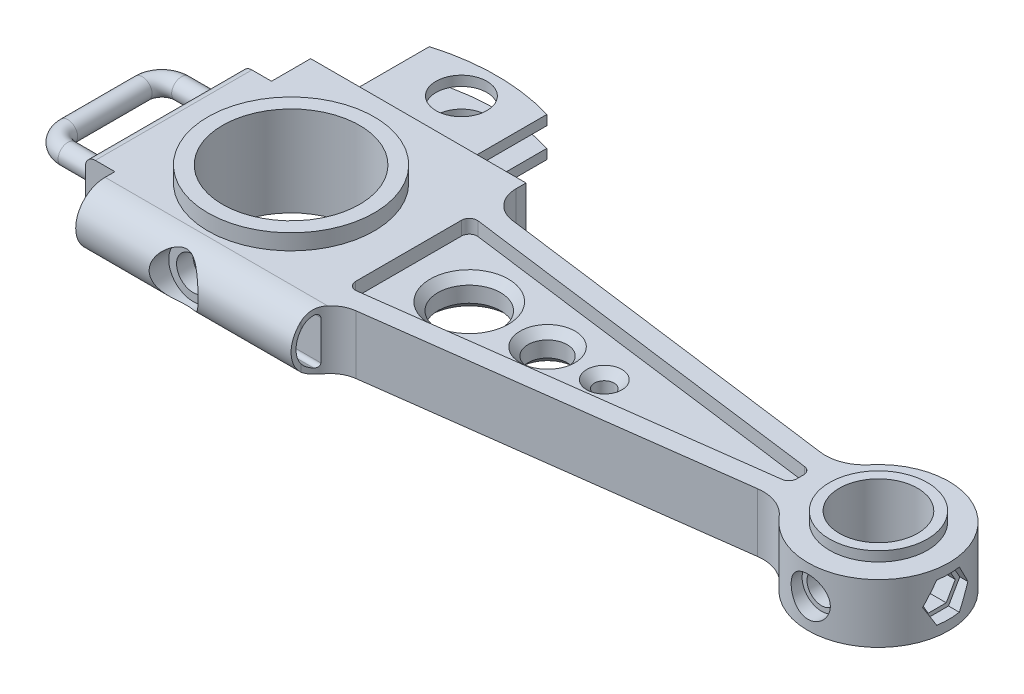
from build123d import *

# Parameters (mm, degrees)
SKETCH1_R           = 22.225
SKETCH1_R_2         = 12.7
BOSS_EXTRUDE2_DEPTH = 9.525
SKETCH3_R           = 15.875
SKETCH3_R_2         = 12.7
BOSS_EXTRUDE3_DEPTH = 12.7
CUT_EXTRUDE5_REACH  = 78.2
SKETCH7_R           = 5.3975
SKETCH8_R           = 7.9375
CUT_EXTRUDE6_DEPTH  = 6.35
SKETCH4_R           = 26.9875
SKETCH4_R_2         = 22.225
BOSS_EXTRUDE4_DEPTH = 14.605
CUT_EXTRUDE2_DEPTH  = 40.64
CUT_EXTRUDE4_DEPTH  = 12.7
SKETCH10_R          = 8.255
BOSS_EXTRUDE5_DEPTH = 6.35
FILLET1_R           = 1.27
SKETCH11_W          = 24.765
SKETCH11_H          = 6.35
CUT_EXTRUDE7_DEPTH  = 61.325
SKETCH12_R          = 3.175
FILLET2_R           = 2.54
FILLET3_R           = 3.175
CUT_EXTRUDE8_DEPTH  = 4.445
SKETCH15_R          = 10.16
SKETCH15_R_2        = 6.35
SKETCH15_R_3        = 3.175
CUT_EXTRUDE9_DEPTH  = 20.685
CHAMFER1_SIZE       = 2.54
SKETCH16_R          = 4.7625
CUT_EXTRUDE10_DEPTH = 39.1000001
CUT_EXTRUDE11_START = 18.415
SKETCH17_R          = 6.35
CUT_EXTRUDE11_DEPTH = 4.445
CUT_EXTRUDE12_START = 190.5
CUT_EXTRUDE12_DEPTH = 23.8600001
CUT_EXTRUDE13_START = 209.55
CUT_EXTRUDE13_DEPTH = 4.8100001


with BuildPart() as part:
    # Sketch1 → Boss-Extrude2 (new body, symmetric)
    with BuildSketch(Plane(origin=(0, 0, 0), x_dir=(1, 0, 0), z_dir=(0, 1, 0))):
        with BuildLine():
            Line((-41.275, 25.4), (-41.275, -25.4))
            Line((-41.275, -25.4), (-31.75, -25.4))
            Line((-31.75, -25.4), (-31.75, -38.1))
            Line((-31.75, -38.1), (38.1, -38.1))
            Line((38.1, -38.1), (38.1, -34.82000081))
            ThreePointArc((38.1, -34.82000081), (40.463725834, -28.539731921), (46.381738019, -25.376488505))
            Line((46.381738019, -25.376488505), (161.557504049, -10.213311246))
            ThreePointArc((161.557504049, -10.213311246), (167.829623981, -10.972629525), (172.959762872, -14.660139205))
            ThreePointArc((172.959762872, -14.660139205), (213.36, 0), (172.959762872, 14.660139205))
            ThreePointArc((172.959762872, 14.660139205), (167.829623981, 10.972629525), (161.557504049, 10.213311246))
            Line((161.557504049, 10.213311246), (46.381738019, 25.376488505))
            ThreePointArc((46.381738019, 25.376488505), (40.463725834, 28.539731921), (38.1, 34.82000081))
            Line((38.1, 34.82000081), (38.1, 38.1))
            Line((38.1, 38.1), (-31.75, 38.1))
            Line((-31.75, 38.1), (-31.75, 25.4))
            Line((-31.75, 25.4), (-41.275, 25.4))
        make_face()
        Circle(SKETCH1_R, mode=Mode.SUBTRACT)
        with Locations((190.5, 0)):
            Circle(SKETCH1_R_2, mode=Mode.SUBTRACT)
    extrude(amount=BOSS_EXTRUDE2_DEPTH, both=True)

    # Sketch3 → Boss-Extrude3 (add, symmetric)
    with BuildSketch(Plane(origin=(0, 0, 0), x_dir=(1, 0, 0), z_dir=(0, 1, 0))):
        with Locations((190.5, 0)):
            Circle(SKETCH3_R)
        with Locations((190.5, 0)):
            Circle(SKETCH3_R_2, mode=Mode.SUBTRACT)
    extrude(amount=BOSS_EXTRUDE3_DEPTH, both=True)

    # Sketch7 → Cut-Extrude5 (cut, up to next)
    with BuildSketch(Plane.XY.offset(38.1), mode=Mode.PRIVATE) as cut_extrude5_sk1:
        Circle(SKETCH7_R)
    cut_extrude5_tool1 = extrude(cut_extrude5_sk1.sketch, amount=-CUT_EXTRUDE5_REACH, mode=Mode.PRIVATE) & part.part
    add(cut_extrude5_tool1.solids().sort_by_distance((0, 0, 38.1))[0], mode=Mode.SUBTRACT)

    # Sketch8 → Cut-Extrude6 (cut)
    with BuildSketch(Plane.XY.offset(38.1)):
        Circle(SKETCH8_R)
    extrude(amount=-CUT_EXTRUDE6_DEPTH, mode=Mode.SUBTRACT)

    # Sketch4 → Boss-Extrude4 (add, symmetric)
    with BuildSketch(Plane(origin=(0, 0, 0), x_dir=(1, 0, 0), z_dir=(0, 1, 0))):
        Circle(SKETCH4_R)
        Circle(SKETCH4_R_2, mode=Mode.SUBTRACT)
    extrude(amount=BOSS_EXTRUDE4_DEPTH, both=True)

    # Sketch5 → Cut-Extrude2 (cut, symmetric)
    with BuildSketch(Plane(origin=(0, 0, 0), x_dir=(0, 0, -1), z_dir=(1, 0, 0))):
        with BuildLine():
            Line((-28.575, 9.525), (-38.1, 9.525))
            Line((-38.1, 9.525), (-38.1, 0))
            ThreePointArc((-38.1, 0), (-35.310192091, 6.735192091), (-28.575, 9.525))
        make_face()
        with BuildLine():
            ThreePointArc((-28.575, -9.525), (-35.310192091, -6.735192091), (-38.1, 0))
            Line((-38.1, 0), (-38.1, -9.525))
            Line((-38.1, -9.525), (-28.575, -9.525))
        make_face()
    extrude(amount=CUT_EXTRUDE2_DEPTH, both=True, mode=Mode.SUBTRACT)

    # Sketch6 → Cut-Extrude4 (cut, symmetric)
    with BuildSketch(Plane(origin=(38.1, 0, 0), x_dir=(0, 0, -1), z_dir=(1, 0, 0))):
        with BuildLine():
            Line((-29.845, 6.337999861), (-29.845, -6.337999861))
            ThreePointArc((-29.845, -6.337999861), (-30.339306083, -7.279087106), (-31.394685393, -7.406202085))
            ThreePointArc((-31.394685393, -7.406202085), (-36.4998, 0), (-31.394685393, 7.406202085))
            ThreePointArc((-31.394685393, 7.406202085), (-30.339306083, 7.279087106), (-29.845, 6.337999861))
        make_face()
    extrude(amount=CUT_EXTRUDE4_DEPTH, both=True, mode=Mode.SUBTRACT)

    # Sketch10 → Boss-Extrude5 (add, symmetric)
    with BuildSketch(Plane(origin=(0, 0, 0), x_dir=(1, 0, 0), z_dir=(0, 1, 0))):
        with BuildLine():
            Line((-19.05, 38.1), (-19.05, 63.895642457))
            ThreePointArc((-19.05, 63.895642457), (0, 66.675), (19.05, 63.895642457))
            Line((19.05, 63.895642457), (19.05, 38.1))
            Line((19.05, 38.1), (-19.05, 38.1))
        make_face()
        with Locations((0, 55.245)):
            Circle(SKETCH10_R, mode=Mode.SUBTRACT)
    extrude(amount=BOSS_EXTRUDE5_DEPTH, both=True)

    # Fillet1
    fillet1_edges = [part.edges().sort_by_distance(p)[0] for p in [
        (0, 6.35, -38.1),
        (0, -6.35, -38.1),
        (-19.05, 0, -38.1),
        (19.05, 0, -38.1),
    ]]
    fillet(fillet1_edges, radius=FILLET1_R)

    # Sketch11 → Cut-Extrude7 (cut, through all)
    with BuildSketch(Plane(origin=(19.05, 0, 0), x_dir=(0, 0, -1), z_dir=(1, 0, 0))):
        with Locations((54.2925, 0)):
            Rectangle(SKETCH11_W, SKETCH11_H)
    extrude(amount=-CUT_EXTRUDE7_DEPTH, mode=Mode.SUBTRACT)

    # Sweep1: sweep along a path in Sketch13
    with BuildLine(Plane(origin=(0, 0, 0), x_dir=(1, 0, 0), z_dir=(0, 1, 0))) as sweep1_path:
        Line((-41.275, -18.415), (-53.975, -18.415))
        ThreePointArc((-53.975, -18.415), (-58.465128061, -16.555128061), (-60.325, -12.065))
        Line((-60.325, -12.065), (-60.325, 12.065))
        ThreePointArc((-60.325, 12.065), (-58.465128061, 16.555128061), (-53.975, 18.415))
        Line((-53.975, 18.415), (-41.275, 18.415))
    # Sketch12 → Sweep1 (sweep)
    with BuildSketch(Plane.ZY.offset(41.275)):
        with Locations((18.415, 0)):
            Circle(SKETCH12_R)
    sweep(path=sweep1_path.line)

    # Fillet2
    fillet2_edges = [part.edges().sort_by_distance(p)[0] for p in [
        (-41.275, 0, 15.24),
        (-41.275, 0, -15.24),
    ]]
    fillet(fillet2_edges, radius=FILLET2_R)

    # Fillet3
    fillet3_edges = [part.edges().sort_by_distance(p)[0] for p in [
        (-41.275, -9.525, 0),
        (-41.275, 9.525, 0),
    ]]
    fillet(fillet3_edges, radius=FILLET3_R)

    # Sketch14 → Cut-Extrude8 (cut)
    with BuildSketch(Plane(origin=(0, 9.525, 0), x_dir=(1, 0, 0), z_dir=(0, 1, 0))):
        with BuildLine():
            Line((38.1, 17.167525729), (38.1, -17.167525729))
            ThreePointArc((38.1, -17.167525729), (38.96526163, -19.07719884), (40.971536528, -19.685795676))
            Line((40.971536528, -19.685795676), (162.891536528, -3.634723171))
            ThreePointArc((162.891536528, -3.634723171), (164.469673111, -2.791191593), (165.1, -1.116453223))
            Line((165.1, -1.116453223), (165.1, 1.116453223))
            ThreePointArc((165.1, 1.116453223), (164.469673111, 2.791191593), (162.891536528, 3.634723171))
            Line((162.891536528, 3.634723171), (40.971536528, 19.685795676))
            ThreePointArc((40.971536528, 19.685795676), (38.96526163, 19.07719884), (38.1, 17.167525729))
        make_face()
    cut_extrude8 = extrude(amount=-CUT_EXTRUDE8_DEPTH, mode=Mode.SUBTRACT)

    # Mirror1: Cut-Extrude8 across plane
    add(cut_extrude8.mirror(Plane.ZX), mode=Mode.SUBTRACT)

    # Sketch15 → Cut-Extrude9 (cut, through all)
    with BuildSketch(Plane(origin=(0, 5.08, 0), x_dir=(1, 0, 0), z_dir=(0, 1, 0))):
        with Locations((57.785, 0)):
            Circle(SKETCH15_R)
        with Locations((83.185, 0)):
            Circle(SKETCH15_R_2)
        with Locations((101.6, 0)):
            Circle(SKETCH15_R_3)
    extrude(amount=-CUT_EXTRUDE9_DEPTH, mode=Mode.SUBTRACT)

    # Chamfer1
    chamfer1_edges = [part.edges().sort_by_distance(p)[0] for p in [
        (47.625, -5.08, 0),
        (47.625, 5.08, 0),
        (76.835, -5.08, 0),
        (76.835, 5.08, 0),
        (98.425, -5.08, 0),
        (98.425, 5.08, 0),
    ]]
    chamfer(chamfer1_edges, length=CHAMFER1_SIZE)

    # Sketch16 → Cut-Extrude10 (cut, through all)
    with BuildSketch(Plane.XY):
        with Locations((190.5, 0)):
            Circle(SKETCH16_R)
    extrude(amount=CUT_EXTRUDE10_DEPTH, mode=Mode.SUBTRACT)

    # Sketch17 → Cut-Extrude11 (cut)
    with BuildSketch(Plane.XY.offset(CUT_EXTRUDE11_START)):
        with Locations((190.5, 0)):
            Circle(SKETCH17_R)
    extrude(amount=CUT_EXTRUDE11_DEPTH, mode=Mode.SUBTRACT)

    # Sketch18 → Cut-Extrude12 (cut, through all)
    with BuildSketch(Plane(origin=(0, 0, 0), x_dir=(0, 0, -1), z_dir=(1, 0, 0)).offset(CUT_EXTRUDE12_START)):
        Polygon((5.865878735, 0), (2.932939367, 5.08), (-2.932939367, 5.08), (-5.865878735, 0), (-2.932939367, -5.08), (2.932939367, -5.08), align=None)
    extrude(amount=CUT_EXTRUDE12_DEPTH, mode=Mode.SUBTRACT)

    # Sketch19 → Cut-Extrude13 (cut, through all)
    with BuildSketch(Plane(origin=(0, 0, 0), x_dir=(0, 0, -1), z_dir=(1, 0, 0)).offset(CUT_EXTRUDE13_START)):
        Polygon((7.332348419, 0), (3.666174209, 6.35), (-3.666174209, 6.35), (-7.332348419, 0), (-3.666174209, -6.35), (3.666174209, -6.35), align=None)
    extrude(amount=CUT_EXTRUDE13_DEPTH, mode=Mode.SUBTRACT)


solid = part.part
